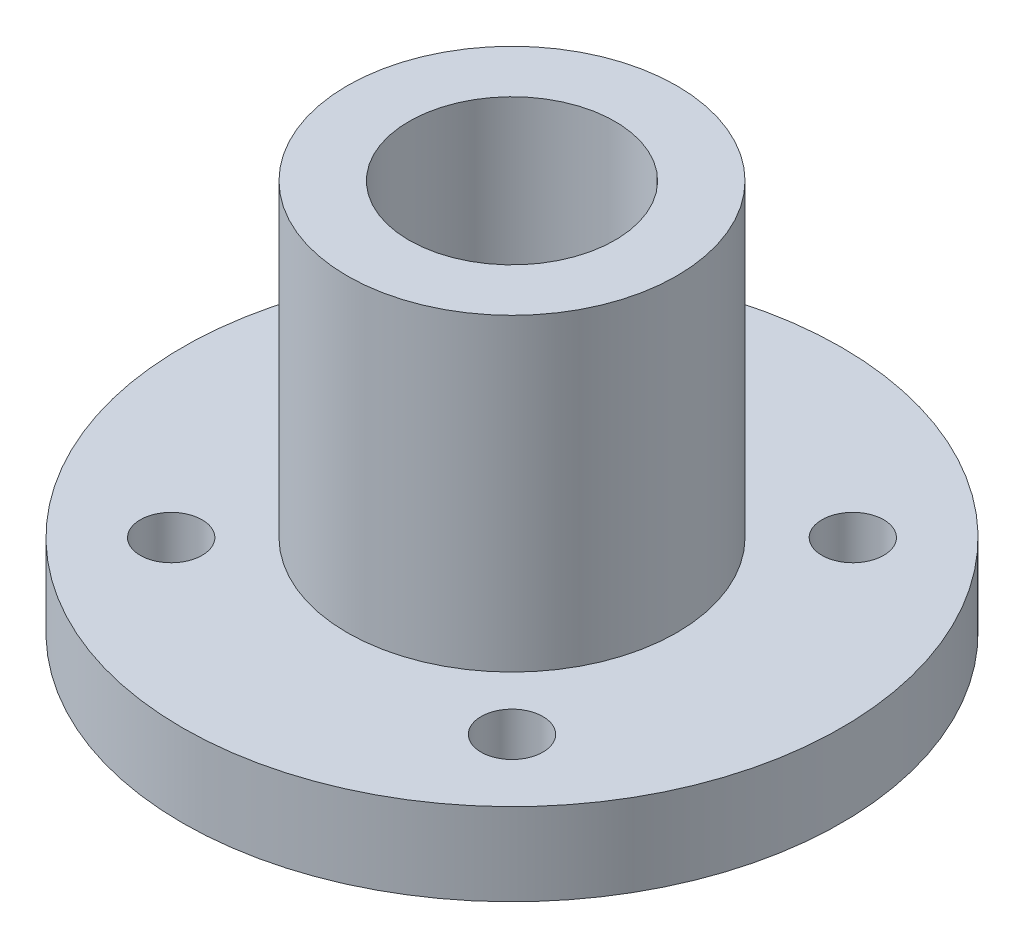
from build123d import *

# Parameters (mm, degrees)
SKETCH1_R           = 16
SKETCH1_R_2         = 1.5
SKETCH1_R_3         = 5
BOSS_EXTRUDE1_DEPTH = 4
SKETCH2_R           = 8
SKETCH2_R_2         = 5
BOSS_EXTRUDE2_DEPTH = 15


with BuildPart() as part:
    # Sketch1 → Boss-Extrude1 (new body)
    with BuildSketch(Plane(origin=(0, 0, 0), x_dir=(1, 0, 0), z_dir=(0, 1, 0))):
        Circle(SKETCH1_R)
        with Locations((8.27314934, -8.27314934)):
            Circle(SKETCH1_R_2, mode=Mode.SUBTRACT)
        Circle(SKETCH1_R_3, mode=Mode.SUBTRACT)
        with Locations((-8.27314934, -8.27314934)):
            Circle(SKETCH1_R_2, mode=Mode.SUBTRACT)
        with Locations((8.27314934, 8.27314934)):
            Circle(SKETCH1_R_2, mode=Mode.SUBTRACT)
        with Locations((-8.27314934, 8.27314934)):
            Circle(SKETCH1_R_2, mode=Mode.SUBTRACT)
    extrude(amount=BOSS_EXTRUDE1_DEPTH)

    # Sketch2 → Boss-Extrude2 (add)
    with BuildSketch(Plane(origin=(0, 4, 0), x_dir=(1, 0, 0), z_dir=(0, 1, 0))):
        Circle(SKETCH2_R)
        Circle(SKETCH2_R_2, mode=Mode.SUBTRACT)
    extrude(amount=BOSS_EXTRUDE2_DEPTH)


solid = part.part
